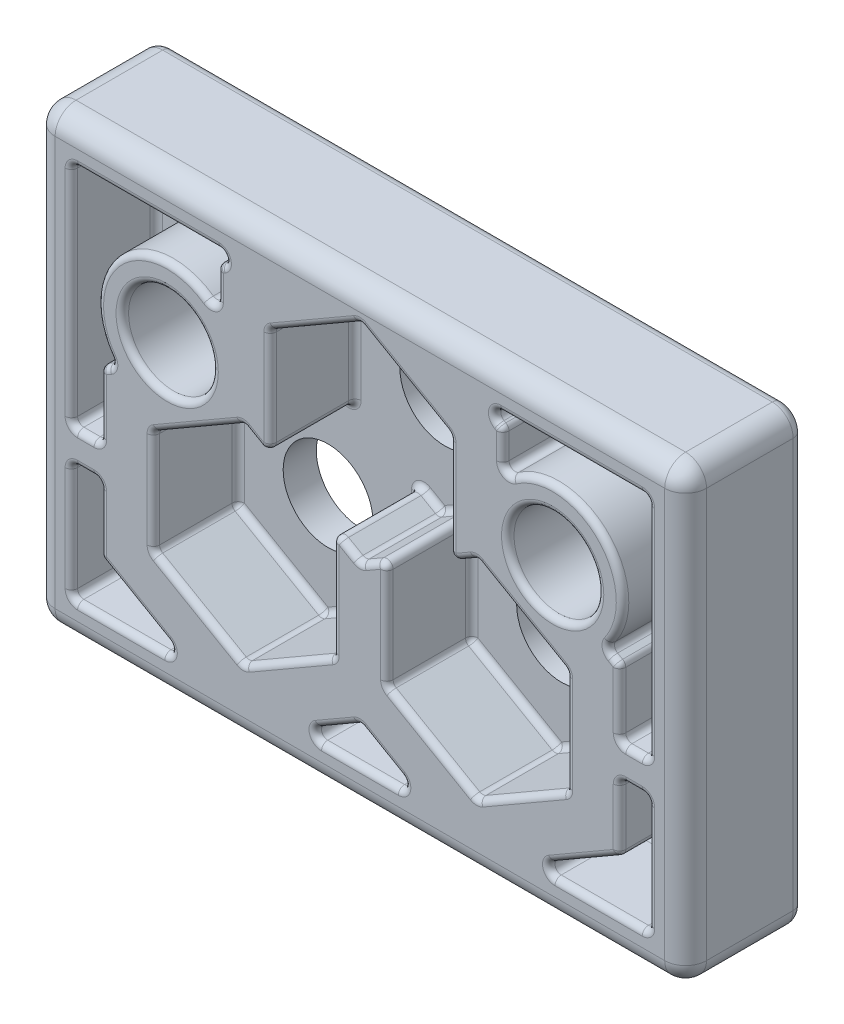
from build123d import *

# Parameters (mm, degrees)
SKETCH1_W           = 31.1912
SKETCH1_H           = 21.59
SKETCH1_R           = 2.14884
BOSS_EXTRUDE1_DEPTH = 5.6515
SKETCH2_R           = 2.14884
CUT_EXTRUDE3_DEPTH  = 4.064
FILLET1_R           = 0.29972
FILLET2_R           = 1.00076
FILLET3_R           = 0.50038


with BuildPart() as part:
    # Sketch1 → Boss-Extrude1 (new body)
    with BuildSketch(Plane.XY):
        Rectangle(SKETCH1_W, SKETCH1_H)
        with Locations(Location((0, 4.37134, 0), (0, 0, 180))):
            Circle(SKETCH1_R, mode=Mode.SUBTRACT)
        with Locations(Location((5.59054, -2.63906, 0), (0, 0, 180))):
            Circle(SKETCH1_R, mode=Mode.SUBTRACT)
        with Locations(Location((-5.59054, -2.63906, 0), (0, 0, 180))):
            Circle(SKETCH1_R, mode=Mode.SUBTRACT)
        with Locations(Location((-9.22909, 3.92176, 0), (0, 0, 180))):
            Circle(SKETCH1_R, mode=Mode.SUBTRACT)
        with Locations(Location((9.22909, 3.92176, 0), (0, 0, 180))):
            Circle(SKETCH1_R, mode=Mode.SUBTRACT)
    extrude(amount=BOSS_EXTRUDE1_DEPTH)

    # Sketch2 → Cut-Extrude3 (cut)
    with BuildSketch(Plane.XY.offset(5.6515)):
        Polygon((0, -7.309765943), (-2.957016128, -9.017), (2.957016128, -9.017), align=None)
        Polygon((-9.89076, -5.121793175), (-5.59054, -7.604526349), (-1.29032, -5.121793175), (-1.29032, 0.15084025), (0, -0.594126349), (1.29032, 0.15084025), (1.29032, -2.782099117), (1.29032, -5.121793175), (5.59054, -7.604526349), (9.89076, -5.121793175), (9.89076, -0.156326825), (5.59054, 2.326406349), (4.30022, 1.58143975), (4.30022, 4.514379117), (4.30022, 6.854073175), (0, 9.336806349), (-4.30022, 6.854073175), (-4.30022, 1.58143975), (-5.59054, 2.326406349), (-9.89076, -0.156326825), align=None)
        with Locations(Location((-5.59054, -2.63906, 0), (0, 0, 180))):
            Circle(SKETCH2_R, mode=Mode.SUBTRACT)
        with Locations(Location((5.59054, -2.63906, 0), (0, 0, 180))):
            Circle(SKETCH2_R, mode=Mode.SUBTRACT)
        with Locations(Location((0, 4.37134, 0), (0, 0, 180))):
            Circle(SKETCH2_R, mode=Mode.SUBTRACT)
        with BuildLine():
            Line((-12.43076, 1.310142858), (-11.740797942, 1.708492638))
            ThreePointArc((-11.740797942, 1.708492638), (-11.509211408, 6.372938403), (-6.84022, 6.267080729))
            Line((-6.84022, 6.267080729), (-6.84022, 8.320542858))
            Line((-6.84022, 8.320542858), (-5.633920845, 9.017))
            Line((-5.633920845, 9.017), (-13.8176, 9.017))
            Line((-13.8176, 9.017), (-13.8176, -1.87706))
            Line((-13.8176, -1.87706), (-12.43076, -1.87706))
            Line((-12.43076, -1.87706), (-12.43076, 1.310142858))
        make_face()
        Polygon((-12.43076, -6.588262858), (-12.43076, -3.40106), (-13.8176, -3.40106), (-13.8176, -9.017), (-8.224063872, -9.017), align=None)
        with BuildLine():
            Line((13.8176, 9.017), (5.633920845, 9.017))
            Line((5.633920845, 9.017), (6.84022, 8.320542858))
            Line((6.84022, 8.320542858), (6.84022, 6.267080729))
            ThreePointArc((6.84022, 6.267080729), (11.509211408, 6.372938403), (11.740797942, 1.708492638))
            Line((11.740797942, 1.708492638), (12.43076, 1.310142858))
            Line((12.43076, 1.310142858), (12.43076, -1.87706))
            Line((12.43076, -1.87706), (13.8176, -1.87706))
            Line((13.8176, -1.87706), (13.8176, 9.017))
        make_face()
        Polygon((13.8176, -9.017), (13.8176, -3.40106), (12.43076, -3.40106), (12.43076, -6.588262858), (8.224063872, -9.017), align=None)
    extrude(amount=-CUT_EXTRUDE3_DEPTH, mode=Mode.SUBTRACT)

    # Fillet1
    fillet1_edges = [part.edges().sort_by_distance(p)[0] for p in [
        (4.30022, 4.217756462, 1.5875),
        (1.29032, -2.485476462, 5.6515),
        (3.44043, -6.363159762, 5.6515),
        (7.74065, -6.363159762, 5.6515),
        (9.89076, -2.63906, 5.6515),
        (7.74065, 1.085039762, 5.6515),
        (4.94538, 1.953923049, 5.6515),
        (2.15011, 8.095439762, 5.6515),
        (-2.15011, 8.095439762, 5.6515),
        (-4.30022, 4.217756462, 5.6515),
        (-4.94538, 1.953923049, 5.6515),
        (-7.74065, 1.085039762, 5.6515),
        (-9.89076, -2.63906, 5.6515),
        (-7.74065, -6.363159762, 5.6515),
        (-3.44043, -6.363159762, 5.6515),
        (-1.29032, -2.485476462, 5.6515),
        (-0.64516, -0.221643049, 5.6515),
        (0.64516, -0.221643049, 5.6515),
        (-12.43076, -4.994661429, 5.6515),
        (-12.43076, -3.40106, 3.6195),
        (-10.327411936, -7.802631429, 5.6515),
        (-12.43076, -6.588262858, 3.6195),
        (-11.020831936, -9.017, 1.5875),
        (-8.224063872, -9.017, 3.6195),
        (-13.8176, -6.20903, 1.5875),
        (-13.8176, -9.017, 3.6195),
        (-13.12418, -3.40106, 1.5875),
        (-13.8176, -3.40106, 3.6195),
        (-12.43076, -4.994661429, 1.5875),
        (-10.327411936, -7.802631429, 1.5875),
        (-13.12418, -3.40106, 5.6515),
        (-13.8176, -6.20903, 5.6515),
        (-11.020831936, -9.017, 5.6515),
        (-7.08025, 3.92176, 5.6515),
        (11.37793, 3.92176, 5.6515),
        (-11.509211408, 6.372938403, 5.6515),
        (-6.84022, 6.267080729, 3.6195),
        (-12.085778971, 1.509317748, 5.6515),
        (-11.740797942, 1.708492638, 3.6195),
        (-12.43076, -0.283458571, 5.6515),
        (-12.43076, 1.310142858, 3.6195),
        (-13.12418, -1.87706, 1.5875),
        (-12.43076, -1.87706, 3.6195),
        (-13.8176, 3.56997, 1.5875),
        (-13.8176, -1.87706, 3.6195),
        (-9.725760423, 9.017, 5.6515),
        (-13.8176, 9.017, 3.6195),
        (-6.237070423, 8.668771429, 5.6515),
        (-5.633920845, 9.017, 3.6195),
        (-6.84022, 7.293811794, 5.6515),
        (-6.84022, 8.320542858, 3.6195),
        (-11.509211408, 6.372938403, 1.5875),
        (-12.085778971, 1.509317748, 1.5875),
        (-12.43076, -0.283458571, 1.5875),
        (-9.725760423, 9.017, 1.5875),
        (-6.237070423, 8.668771429, 1.5875),
        (-6.84022, 7.293811794, 1.5875),
        (-13.8176, 3.56997, 5.6515),
        (-13.12418, -1.87706, 5.6515),
        (11.509211408, 6.372938403, 5.6515),
        (11.740797942, 1.708492638, 3.6195),
        (6.84022, 7.293811794, 5.6515),
        (6.84022, 6.267080729, 3.6195),
        (6.237070423, 8.668771429, 5.6515),
        (6.84022, 8.320542858, 3.6195),
        (9.725760423, 9.017, 5.6515),
        (5.633920845, 9.017, 3.6195),
        (13.8176, 3.56997, 5.6515),
        (13.8176, 9.017, 3.6195),
        (13.12418, -1.87706, 1.5875),
        (13.8176, -1.87706, 3.6195),
        (12.43076, -0.283458571, 5.6515),
        (12.43076, -1.87706, 3.6195),
        (12.085778971, 1.509317748, 5.6515),
        (12.43076, 1.310142858, 3.6195),
        (11.509211408, 6.372938403, 1.5875),
        (6.84022, 7.293811794, 1.5875),
        (6.237070423, 8.668771429, 1.5875),
        (9.725760423, 9.017, 1.5875),
        (13.8176, 3.56997, 1.5875),
        (12.43076, -0.283458571, 1.5875),
        (12.085778971, 1.509317748, 1.5875),
        (13.12418, -1.87706, 5.6515),
        (10.327411936, -7.802631429, 5.6515),
        (8.224063872, -9.017, 3.6195),
        (12.43076, -4.994661429, 5.6515),
        (12.43076, -6.588262858, 3.6195),
        (13.12418, -3.40106, 1.5875),
        (12.43076, -3.40106, 3.6195),
        (13.8176, -6.20903, 5.6515),
        (13.8176, -3.40106, 3.6195),
        (11.020831936, -9.017, 1.5875),
        (13.8176, -9.017, 3.6195),
        (10.327411936, -7.802631429, 1.5875),
        (12.43076, -4.994661429, 1.5875),
        (13.8176, -6.20903, 1.5875),
        (11.020831936, -9.017, 5.6515),
        (13.12418, -3.40106, 5.6515),
        (-1.478508064, -8.163382971, 5.6515),
        (-2.957016128, -9.017, 3.6195),
        (1.478508064, -8.163382971, 5.6515),
        (0, -7.309765943, 3.6195),
        (0, -9.017, 1.5875),
        (2.957016128, -9.017, 3.6195),
        (-1.478508064, -8.163382971, 1.5875),
        (1.478508064, -8.163382971, 1.5875),
        (0, -9.017, 5.6515),
        (1.29032, -2.485476462, 1.5875),
        (1.29032, -5.121793175, 3.6195),
        (0.64516, -0.221643049, 1.5875),
        (1.29032, 0.15084025, 3.6195),
        (-0.64516, -0.221643049, 1.5875),
        (0, -0.594126349, 3.6195),
        (-1.29032, -2.485476462, 1.5875),
        (-1.29032, 0.15084025, 3.6195),
        (-3.44043, -6.363159762, 1.5875),
        (-1.29032, -5.121793175, 3.6195),
        (-7.74065, -6.363159762, 1.5875),
        (-5.59054, -7.604526349, 3.6195),
        (-9.89076, -2.63906, 1.5875),
        (-9.89076, -5.121793175, 3.6195),
        (-7.74065, 1.085039762, 1.5875),
        (-9.89076, -0.156326825, 3.6195),
        (-4.94538, 1.953923049, 1.5875),
        (-5.59054, 2.326406349, 3.6195),
        (-4.30022, 4.217756462, 1.5875),
        (-4.30022, 1.58143975, 3.6195),
        (-2.15011, 8.095439762, 1.5875),
        (-4.30022, 6.854073175, 3.6195),
        (2.15011, 8.095439762, 1.5875),
        (0, 9.336806349, 3.6195),
        (4.30022, 4.217756462, 5.6515),
        (4.30022, 6.854073175, 3.6195),
        (4.94538, 1.953923049, 1.5875),
        (4.30022, 1.58143975, 3.6195),
        (7.74065, 1.085039762, 1.5875),
        (5.59054, 2.326406349, 3.6195),
        (9.89076, -2.63906, 1.5875),
        (9.89076, -0.156326825, 3.6195),
        (7.74065, -6.363159762, 1.5875),
        (9.89076, -5.121793175, 3.6195),
        (3.44043, -6.363159762, 1.5875),
        (5.59054, -7.604526349, 3.6195),
    ]]
    fillet(fillet1_edges, radius=FILLET1_R)

    # Fillet2
    fillet2_edges = [part.edges().sort_by_distance(p)[0] for p in [
        (-15.5956, 0, 5.6515),
        (0, -10.795, 5.6515),
        (15.5956, 0, 5.6515),
        (0, 10.795, 5.6515),
        (15.5956, -10.795, 2.82575),
        (-15.5956, -10.795, 2.82575),
        (-15.5956, 10.795, 2.82575),
        (15.5956, 10.795, 2.82575),
    ]]
    fillet(fillet2_edges, radius=FILLET2_R)

    # Fillet3
    fillet3_edges = [part.edges().sort_by_distance(p)[0] for p in [
        (0, 10.795, 0),
        (15.5956, 0, 0),
        (0, -10.795, 0),
        (-15.5956, 0, 0),
        (-15.302484182, 10.501884182, 0),
        (-15.302484182, -10.501884182, 0),
        (15.302484182, -10.501884182, 0),
        (15.302484182, 10.501884182, 0),
    ]]
    fillet(fillet3_edges, radius=FILLET3_R)


solid = part.part
